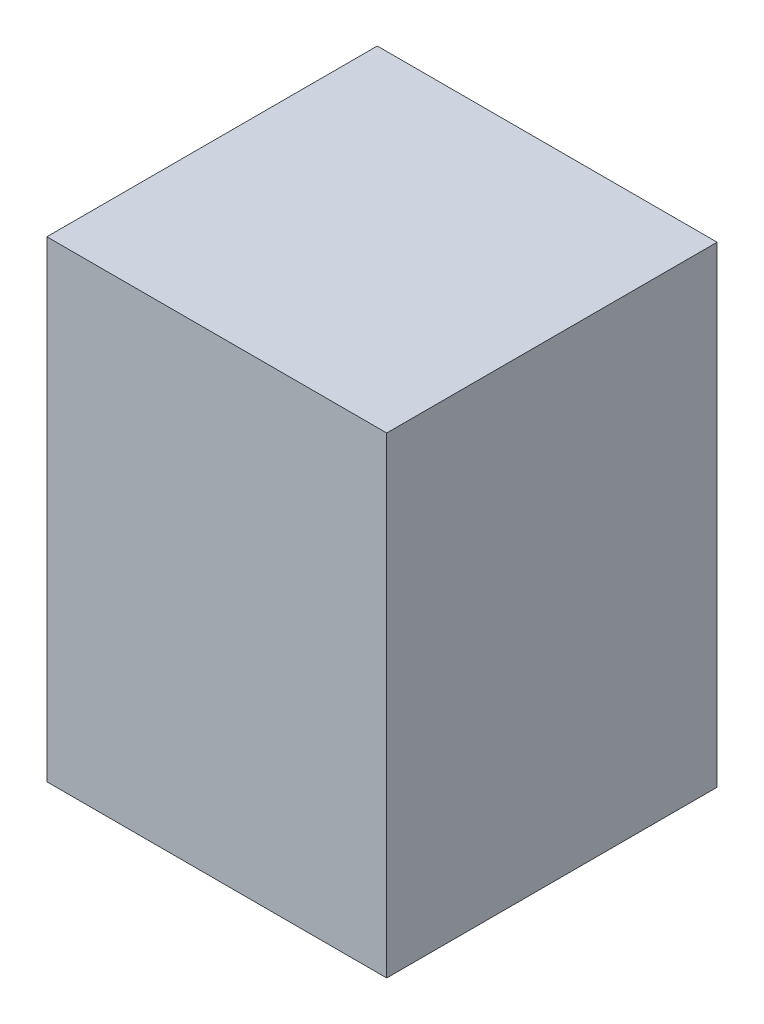
from build123d import *

# Parameters (mm, degrees)
SKETCH1_W           = 72
SKETCH1_H           = 70
BOSS_EXTRUDE1_DEPTH = 100


with BuildPart() as part:
    # Sketch1 → Boss-Extrude1 (new body)
    with BuildSketch(Plane(origin=(0, 0, 0), x_dir=(1, 0, 0), z_dir=(0, 1, 0))):
        with Locations((36, 35)):
            Rectangle(SKETCH1_W, SKETCH1_H)
    extrude(amount=BOSS_EXTRUDE1_DEPTH)


solid = part.part
